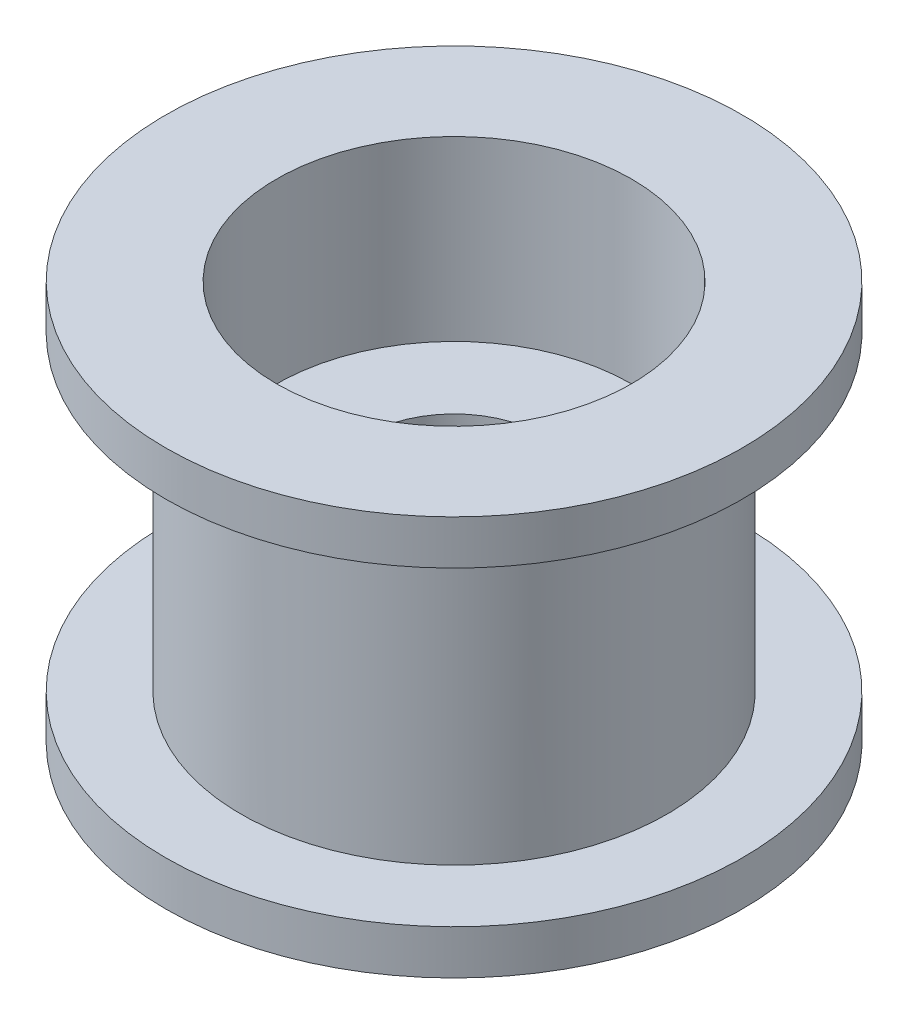
from build123d import *

# Parameters (mm, degrees)
SKETCH2_R           = 4.8
BOSS_EXTRUDE1_DEPTH = 3.5
SKETCH3_R           = 6.5
BOSS_EXTRUDE2_DEPTH = 1
SKETCH4_R           = 4
CUT_EXTRUDE1_DEPTH  = 4
SKETCH5_R           = 2
CUT_EXTRUDE2_DEPTH  = 6


with BuildPart() as part:
    # Sketch2 → Boss-Extrude1 (new body, symmetric)
    with BuildSketch(Plane(origin=(0, 0, 0), x_dir=(1, 0, 0), z_dir=(0, 1, 0))):
        Circle(SKETCH2_R)
    extrude(amount=BOSS_EXTRUDE1_DEPTH, both=True)

    # Sketch3 → Boss-Extrude2 (add)
    with BuildSketch(Plane(origin=(0, 3.5, 0), x_dir=(1, 0, 0), z_dir=(0, 1, 0))):
        Circle(SKETCH3_R)
    boss_extrude2 = extrude(amount=BOSS_EXTRUDE2_DEPTH)

    # Sketch4 → Cut-Extrude1 (cut)
    with BuildSketch(Plane(origin=(0, 4.5, 0), x_dir=(1, 0, 0), z_dir=(0, 1, 0))):
        Circle(SKETCH4_R)
    cut_extrude1 = extrude(amount=-CUT_EXTRUDE1_DEPTH, mode=Mode.SUBTRACT)

    # Mirror1: Boss-Extrude2, Cut-Extrude1 across plane
    add(boss_extrude2.mirror(Plane.ZX))
    add(cut_extrude1.mirror(Plane.ZX), mode=Mode.SUBTRACT)

    # Sketch5 → Cut-Extrude2 (cut, through all)
    with BuildSketch(Plane(origin=(0, 0.5, 0), x_dir=(1, 0, 0), z_dir=(0, 1, 0))):
        Circle(SKETCH5_R)
    extrude(amount=-CUT_EXTRUDE2_DEPTH, mode=Mode.SUBTRACT)


solid = part.part
